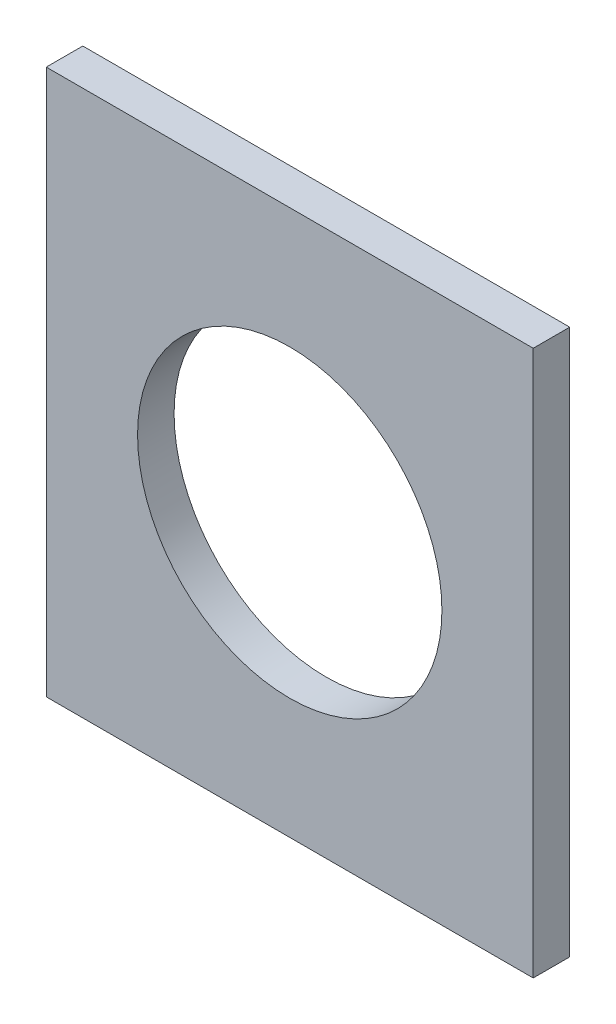
from build123d import *

# Parameters (mm, degrees)
ESQUISSE1_W        = 40
ESQUISSE1_H        = 44.8
ESQUISSE1_R        = 12.5
BOSS_EXTRU_1_DEPTH = 3


with BuildPart() as part:
    # Esquisse1 → Boss.-Extru.1 (new body)
    with BuildSketch(Plane.XY):
        with Locations((-10.638634092, -6.538765295)):
            Rectangle(ESQUISSE1_W, ESQUISSE1_H)
        with Locations((-10.638634092, -6.538765295)):
            Circle(ESQUISSE1_R, mode=Mode.SUBTRACT)
    extrude(amount=BOSS_EXTRU_1_DEPTH)


solid = part.part
